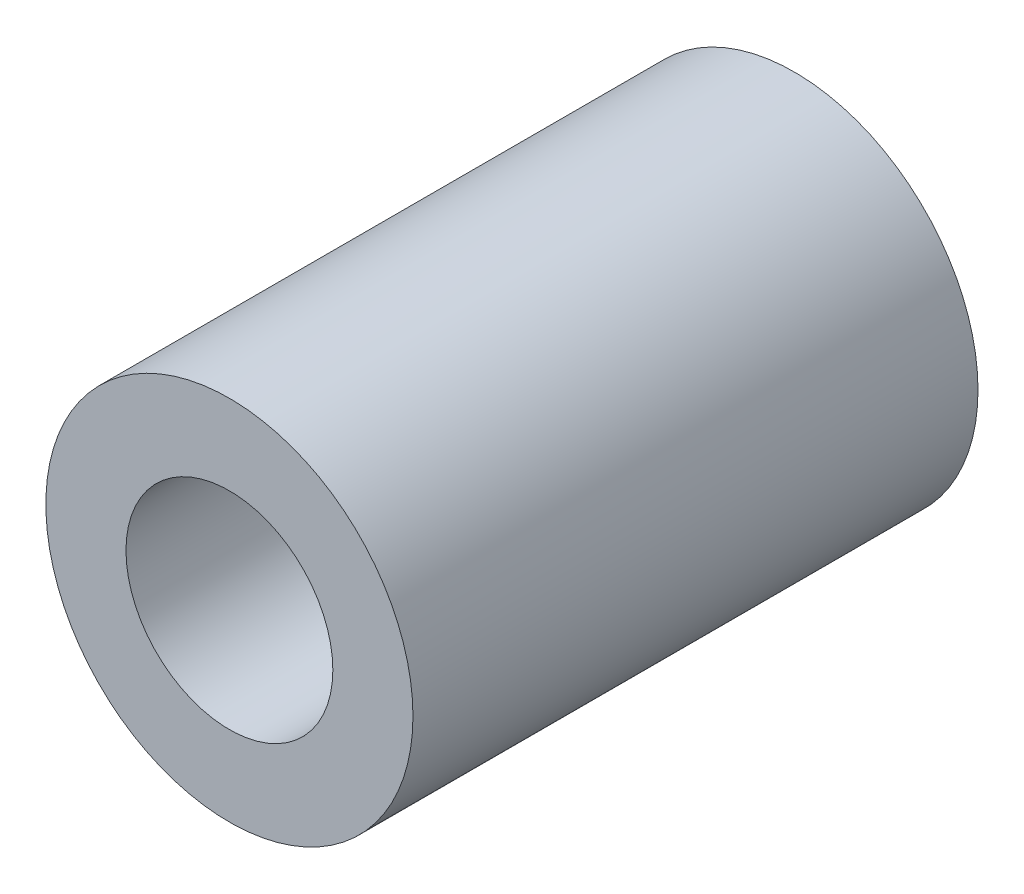
from build123d import *

# Parameters (mm, degrees)
SKETCH1_R           = 5.945
SKETCH1_R_2         = 3.35
BOSS_EXTRUDE1_DEPTH = 18.3


with BuildPart() as part:
    # Sketch1 → Boss-Extrude1 (new body)
    with BuildSketch(Plane.XY):
        Circle(SKETCH1_R)
        Circle(SKETCH1_R_2, mode=Mode.SUBTRACT)
    extrude(amount=BOSS_EXTRUDE1_DEPTH)


solid = part.part
